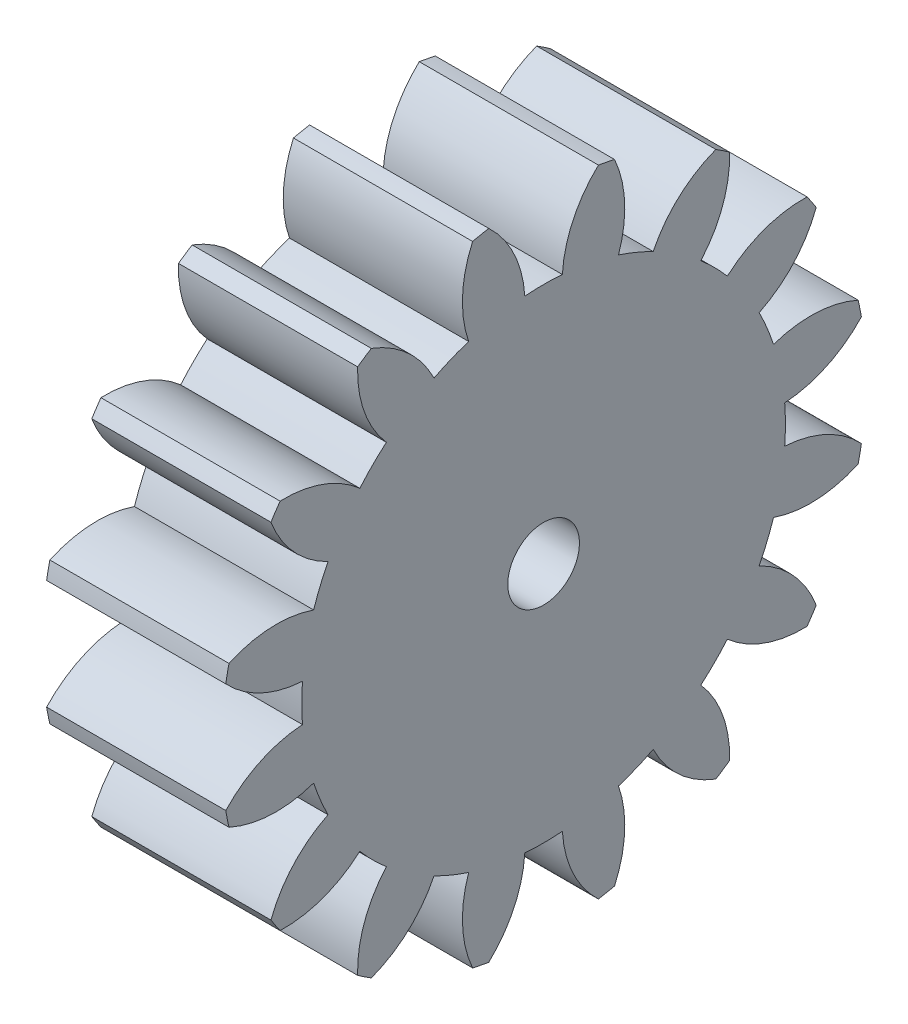
from build123d import *

# Parameters (mm, degrees)
BASPROSKE_W     = 5
BASPROSKE_H     = 9
TOOTHCUT_DEPTH  = 14.674794331
TEETHCUTS_COUNT = 16
TEETHCUTS_ANGLE = 337.5
BORSKE_R        = 1
BORE_DEPTH      = 50.0000508


with BuildPart() as part:
    # BasProSke → Base-Revolve (revolve)
    with BuildSketch(Plane(origin=(0, 0, 0), x_dir=(1, 0, 0), z_dir=(0, 1, 0))):
        with Locations((2.5, 4.5)):
            Rectangle(BASPROSKE_W, BASPROSKE_H)
    revolve(axis=Axis((-10, 0, 0), (1, 0, 0)))

    # TooCutSke → ToothCut (cut, through all)
    with BuildSketch(Plane(origin=(0, 0, 0), x_dir=(0, 0, -1), z_dir=(1, 0, 0))):
        with BuildLine():
            ThreePointArc((0.523792937, 6.728643397), (0, 6.749), (-0.523792937, 6.728643397))
            ThreePointArc((-0.523792937, 6.728643397), (-0.828704482, 7.90962059), (-1.553355277, 8.890721711))
            ThreePointArc((-1.553355277, 8.890721711), (0, 9.0254), (1.553355277, 8.890721711))
            ThreePointArc((1.553355277, 8.890721711), (0.828704482, 7.90962059), (0.523792937, 6.728643397))
        make_face()
    toothcut = extrude(amount=TOOTHCUT_DEPTH, mode=Mode.SUBTRACT)

    # TeethCuts: ToothCut ×16 about axis
    teethcuts_axis = Axis((-10, 0, 0), (1, 0, 0))
    for i in range(1, TEETHCUTS_COUNT):
        add(toothcut.rotate(teethcuts_axis, i * TEETHCUTS_ANGLE / (TEETHCUTS_COUNT - 1)), mode=Mode.SUBTRACT)

    # BorSke → Bore (cut, symmetric)
    with BuildSketch(Plane(origin=(0, 0, 0), x_dir=(0, 0, -1), z_dir=(1, 0, 0))):
        Circle(BORSKE_R)
    extrude(amount=BORE_DEPTH, both=True, mode=Mode.SUBTRACT)


solid = part.part
